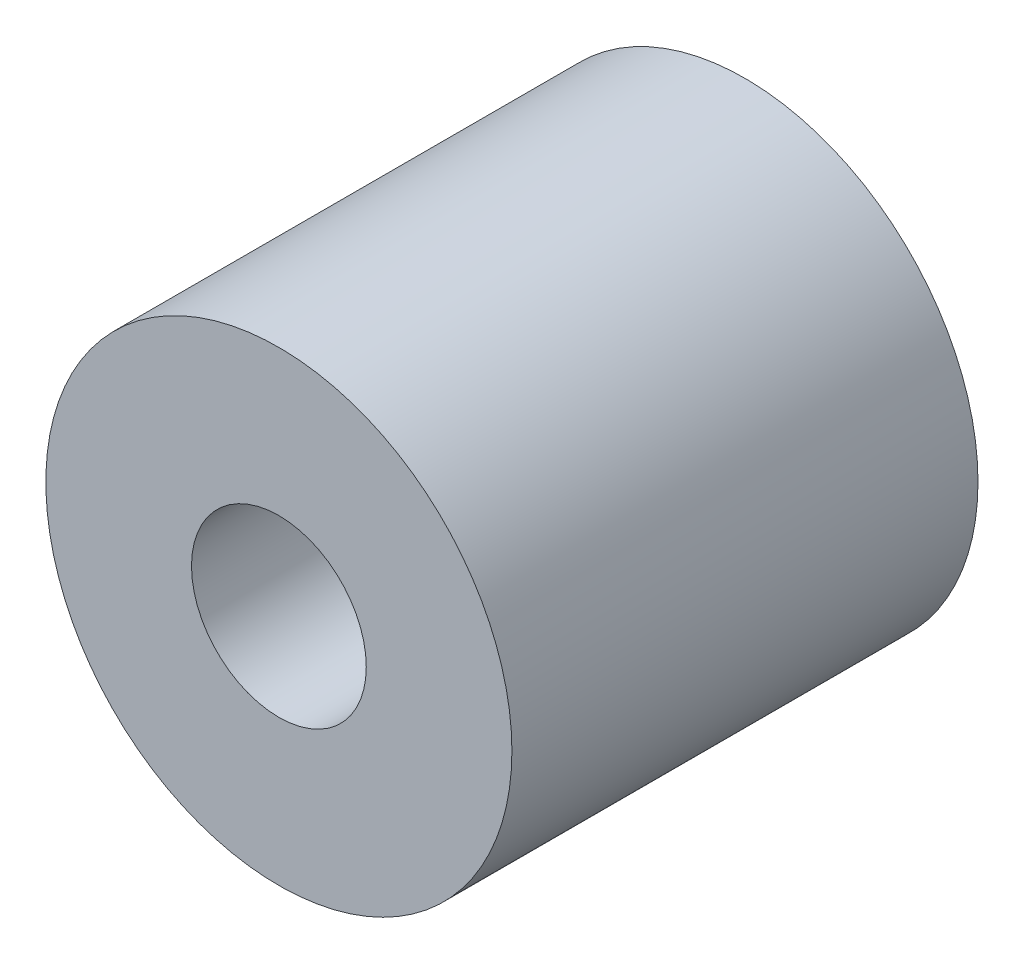
from build123d import *

# Parameters (mm, degrees)
SCHIZZO1_R                   = 4
SCHIZZO1_R_2                 = 1.5
ESTRUSIONE_ESTRUSIONE1_DEPTH = 8


with BuildPart() as part:
    # Schizzo1 → Estrusione-Estrusione1 (new body)
    with BuildSketch(Plane.XY):
        Circle(SCHIZZO1_R)
        Circle(SCHIZZO1_R_2, mode=Mode.SUBTRACT)
    extrude(amount=ESTRUSIONE_ESTRUSIONE1_DEPTH)


solid = part.part
